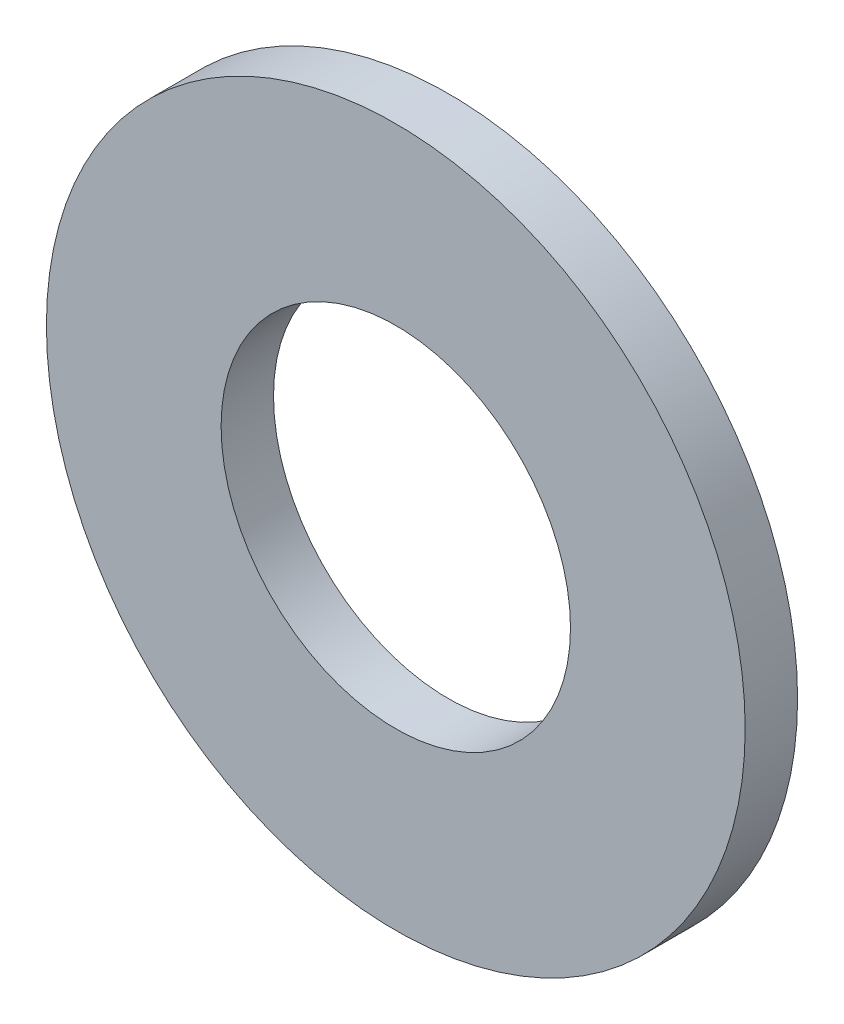
from build123d import *

# Parameters (mm, degrees)
SKETCH1_R           = 4
SKETCH1_R_2         = 2
BOSS_EXTRUDE1_DEPTH = 0.6


with BuildPart() as part:
    # Sketch1 → Boss-Extrude1 (new body)
    with BuildSketch(Plane.XY):
        Circle(SKETCH1_R)
        Circle(SKETCH1_R_2, mode=Mode.SUBTRACT)
    extrude(amount=BOSS_EXTRUDE1_DEPTH)


solid = part.part
